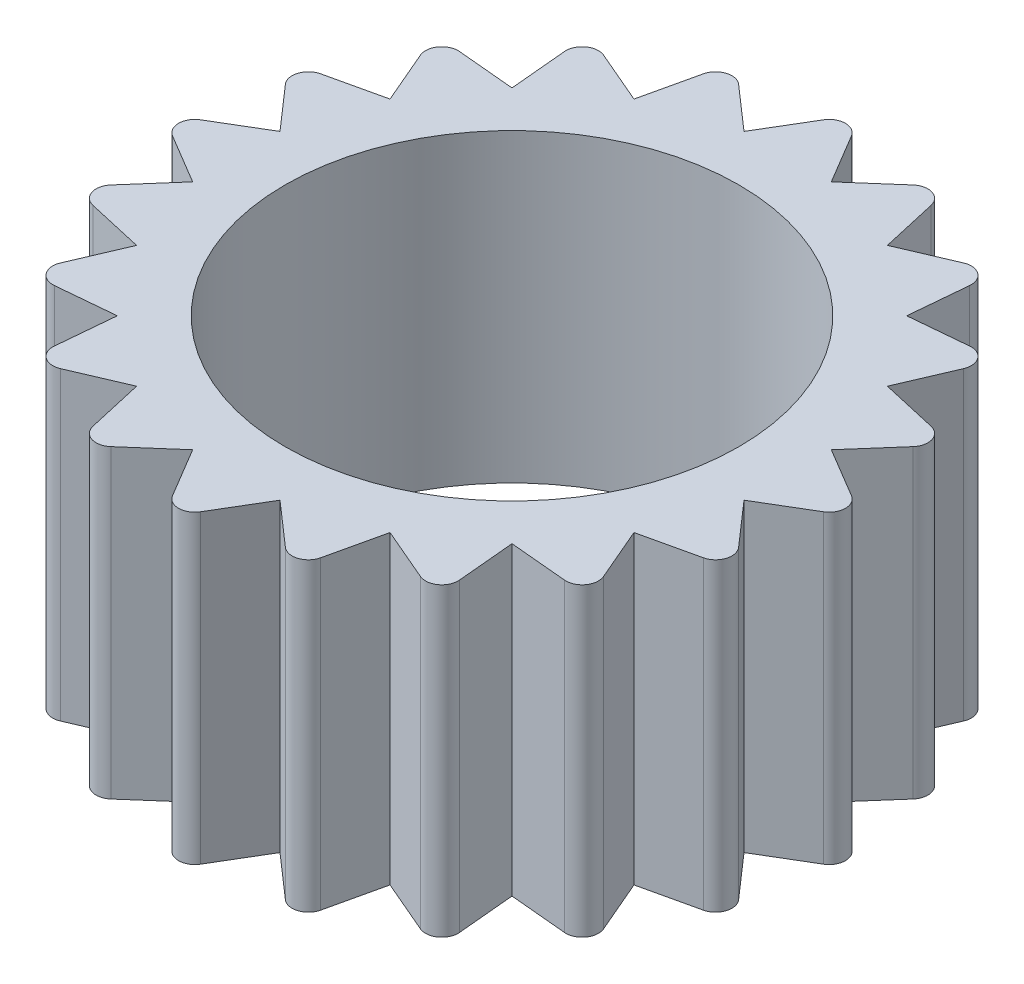
from build123d import *

# Parameters (mm, degrees)
SKETCH1_R           = 11.15
BOSS_EXTRUDE1_DEPTH = 15
FILLET3_R           = 0.8


with BuildPart() as part:
    # Sketch1 → Boss-Extrude1 (new body)
    with BuildSketch(Plane(origin=(0, 0, 0), x_dir=(1, 0, 0), z_dir=(0, 1, 0))):
        Polygon((0, 17.15), (2.145893606, 13.548639006), (5.299641454, 16.310619254), (6.227625801, 12.222403821), (10.080517077, 13.874641454), (9.699754592, 9.699754592), (13.874641454, 10.080517077), (12.222403821, 6.227625801), (16.310619254, 5.299641454), (13.548639006, 2.145893606), (17.15, 0), (13.548639006, -2.145893606), (16.310619254, -5.299641454), (12.222403821, -6.227625801), (13.874641454, -10.080517077), (9.699754592, -9.699754592), (10.080517077, -13.874641454), (6.227625801, -12.222403821), (5.299641454, -16.310619254), (2.145893606, -13.548639006), (0, -17.15), (-2.145893606, -13.548639006), (-5.299641454, -16.310619254), (-6.227625801, -12.222403821), (-10.080517077, -13.874641454), (-9.699754592, -9.699754592), (-13.874641454, -10.080517077), (-12.222403821, -6.227625801), (-16.310619254, -5.299641454), (-13.548639006, -2.145893606), (-17.15, 0), (-13.548639006, 2.145893606), (-16.310619254, 5.299641454), (-12.222403821, 6.227625801), (-13.874641454, 10.080517077), (-9.699754592, 9.699754592), (-10.080517077, 13.874641454), (-6.227625801, 12.222403821), (-5.299641454, 16.310619254), (-2.145893606, 13.548639006), align=None)
        Circle(SKETCH1_R, mode=Mode.SUBTRACT)
    extrude(amount=BOSS_EXTRUDE1_DEPTH)

    # Fillet3
    fillet3_edges = [part.edges().sort_by_distance(p)[0] for p in [
        (0, 7.5, -17.15),
        (5.299641454, 7.5, -16.310619254),
        (10.080517077, 7.5, -13.874641454),
        (13.874641454, 7.5, -10.080517077),
        (16.310619254, 7.5, -5.299641454),
        (17.15, 7.5, 0),
        (16.310619254, 7.5, 5.299641454),
        (13.874641454, 7.5, 10.080517077),
        (10.080517077, 7.5, 13.874641454),
        (5.299641454, 7.5, 16.310619254),
        (0, 7.5, 17.15),
        (-5.299641454, 7.5, 16.310619254),
        (-10.080517077, 7.5, 13.874641454),
        (-13.874641454, 7.5, 10.080517077),
        (-16.310619254, 7.5, 5.299641454),
        (-17.15, 7.5, 0),
        (-16.310619254, 7.5, -5.299641454),
        (-13.874641454, 7.5, -10.080517077),
        (-10.080517077, 7.5, -13.874641454),
        (-5.299641454, 7.5, -16.310619254),
    ]]
    fillet(fillet3_edges, radius=FILLET3_R)


solid = part.part
